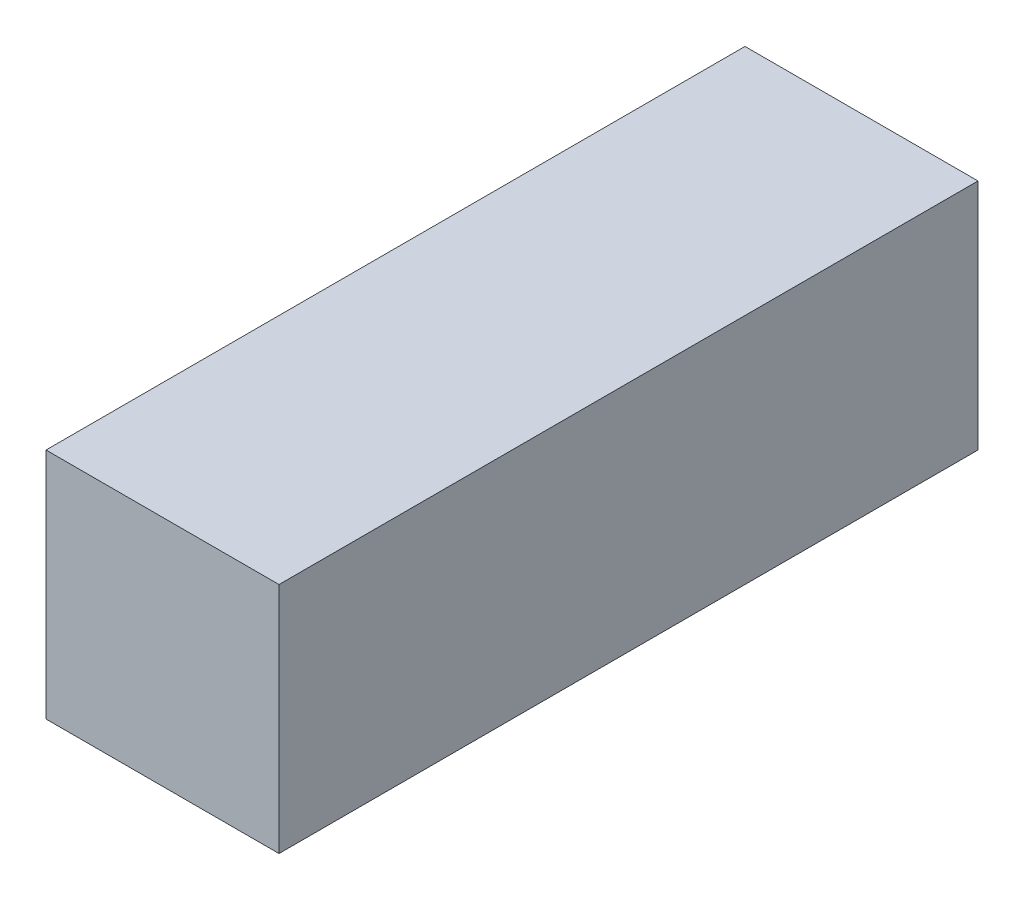
from build123d import *

# Parameters (mm, degrees)
SKETCH2_W           = 3.175
SKETCH2_H           = 3.175
BOSS_EXTRUDE1_DEPTH = 9.525


with BuildPart() as part:
    # Sketch2 → Boss-Extrude1 (new body)
    with BuildSketch(Plane.XY):
        Rectangle(SKETCH2_W, SKETCH2_H)
    extrude(amount=BOSS_EXTRUDE1_DEPTH)


solid = part.part
